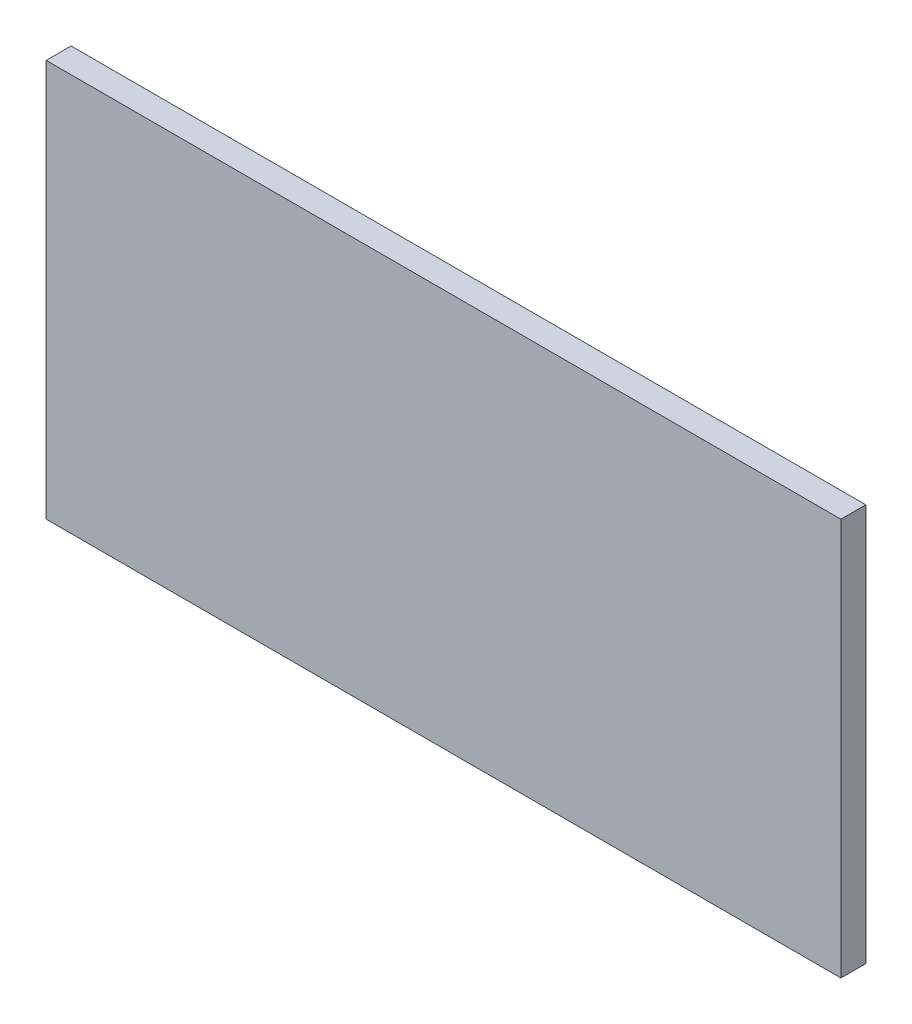
from build123d import *

# Parameters (mm, degrees)
SKETCH1_W           = 381
SKETCH1_H           = 190.5
BOSS_EXTRUDE1_DEPTH = 11.938


with BuildPart() as part:
    # Sketch1 → Boss-Extrude1 (new body)
    with BuildSketch(Plane.XY):
        Rectangle(SKETCH1_W, SKETCH1_H)
    extrude(amount=BOSS_EXTRUDE1_DEPTH)


solid = part.part
